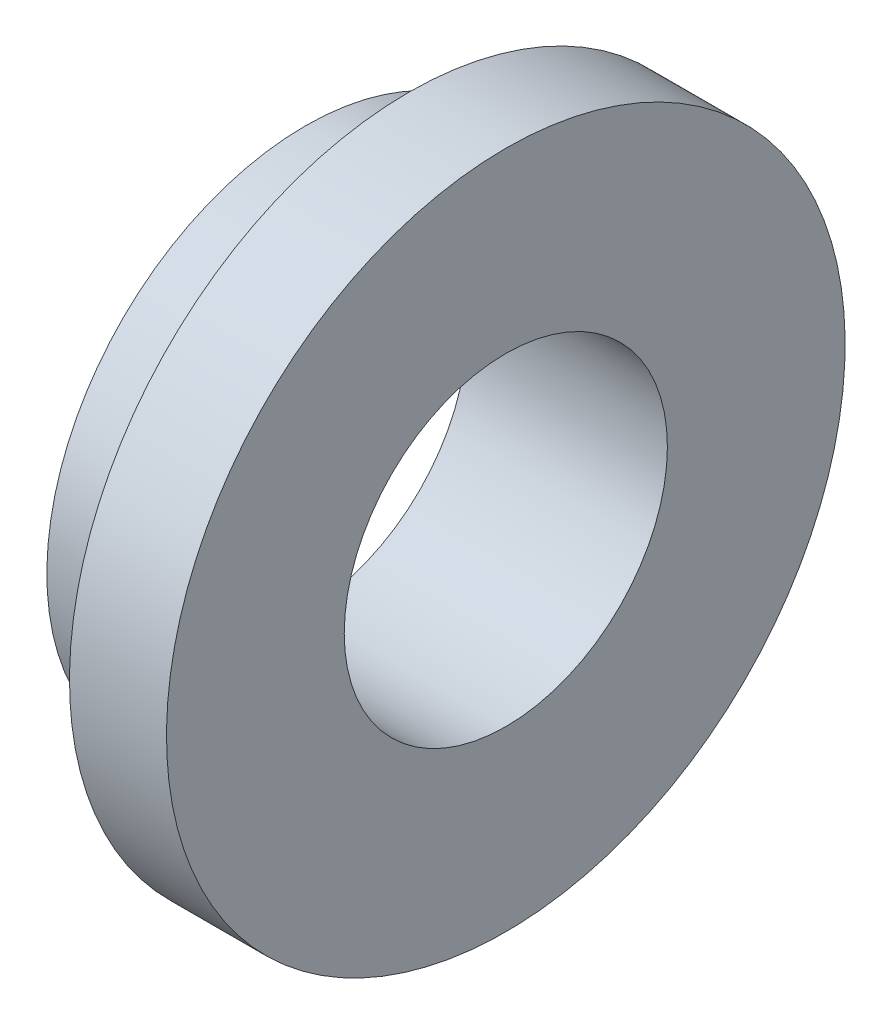
from build123d import *


with BuildPart() as part:
    # Sketch1 → Revolve1 (revolve)
    with BuildSketch(Plane.XY):
        Polygon((-2.46126, 3.175), (-1.19126, 3.175), (-1.19126, 4.1671875), (0, 4.1671875), (0, 1.984375), (-2.46126, 1.984375), align=None)
    revolve(axis=Axis((12.996802453, 0, 0), (-1, 0, 0)))


solid = part.part
